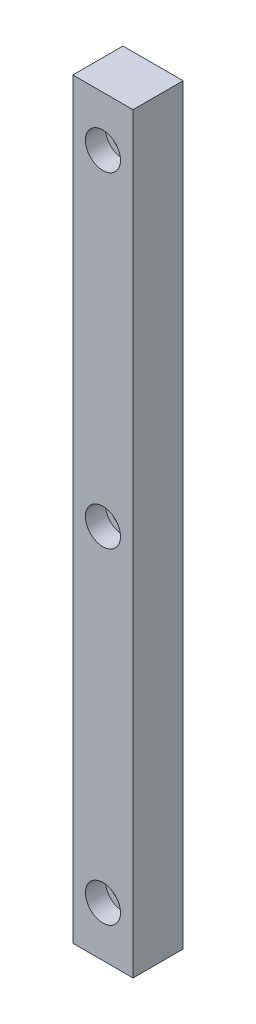
from build123d import *

# Parameters (mm, degrees)
CROQUIS1_W              = 12
CROQUIS1_H              = 150
CROQUIS1_R              = 2.25
SALIENTE_EXTRUIR1_DEPTH = 10
CROQUIS2_R              = 3.5
CORTAR_EXTRUIR1_DEPTH   = 4


with BuildPart() as part:
    # Croquis1 → Saliente-Extruir1 (new body)
    with BuildSketch(Plane.XY):
        Rectangle(CROQUIS1_W, CROQUIS1_H)
        with Locations((0, 65)):
            Circle(CROQUIS1_R, mode=Mode.SUBTRACT)
        Circle(CROQUIS1_R, mode=Mode.SUBTRACT)
        with Locations((0, -65)):
            Circle(CROQUIS1_R, mode=Mode.SUBTRACT)
    extrude(amount=SALIENTE_EXTRUIR1_DEPTH)

    # Croquis2 → Cortar-Extruir1 (cut)
    with BuildSketch(Plane.XY.offset(10)):
        with Locations((0, 65)):
            Circle(CROQUIS2_R)
        Circle(CROQUIS2_R)
        with Locations((0, -65)):
            Circle(CROQUIS2_R)
    extrude(amount=-CORTAR_EXTRUIR1_DEPTH, mode=Mode.SUBTRACT)


solid = part.part
